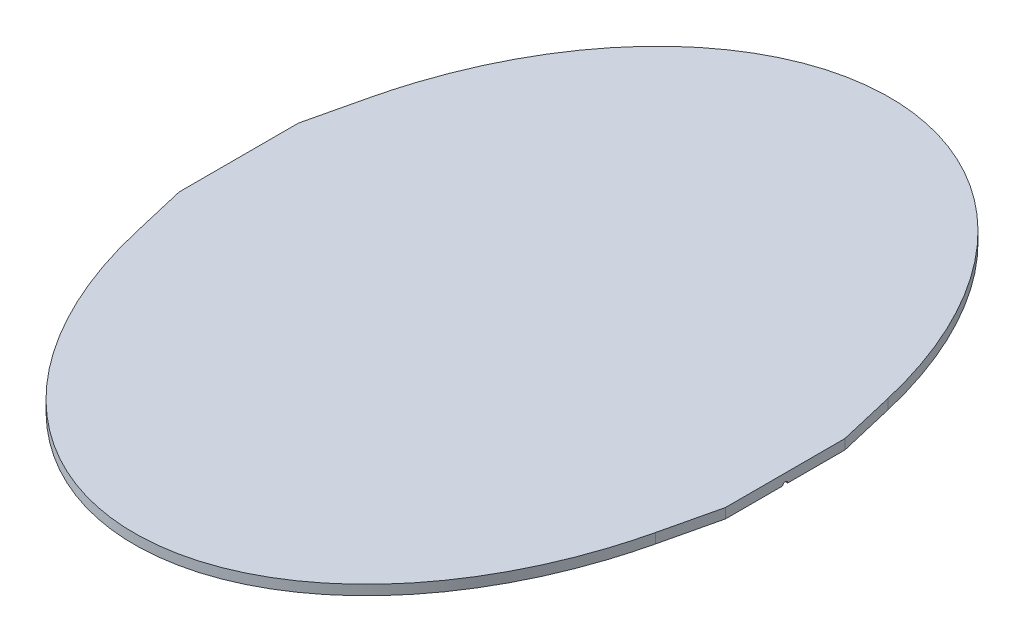
from build123d import *

# Parameters (mm, degrees)
SKETCH1_RX          = 380
SKETCH1_RY          = 275
BOSS_EXTRUDE1_DEPTH = 10
BOSS_EXTRUDE2_DEPTH = 10
CUT_EXTRUDE1_DEPTH  = 10
CUT_EXTRUDE2_DEPTH  = 10


with BuildPart() as part:
    # Sketch1 → Boss-Extrude1 (new body)
    with BuildSketch(Plane(origin=(0, 0, 0), x_dir=(1, 0, 0), z_dir=(0, 1, 0))):
        with Locations(Location((0, 0), (0, 0, 90))):
            Ellipse(SKETCH1_RX, SKETCH1_RY)
    extrude(amount=BOSS_EXTRUDE1_DEPTH)

    # Sketch2 → Boss-Extrude2 (add)
    with BuildSketch(Plane(origin=(0, 10, 0), x_dir=(-1, 0, 0), z_dir=(0, 1, 0))):
        Polygon((-261.621621622, -117.081081081), (-275, -60), (-275, 0), (-275, 60), (-261.621621622, 117.081081081), align=None)
        Polygon((261.621621622, 117.081081081), (261.621621622, -117.081081081), (275, -60), (275, 0), (275, 60), align=None)
    extrude(amount=-BOSS_EXTRUDE2_DEPTH)

    # Sketch3 → Cut-Extrude1 (cut)
    with BuildSketch(Plane(origin=(275, 0, 0), x_dir=(0, 0, -1), z_dir=(1, 0, 0))):
        with BuildLine():
            Line((-2.5, 0), (2.5, 0))
            ThreePointArc((2.5, 0), (0, 2.5), (-2.5, 0))
        make_face()
    extrude(amount=-CUT_EXTRUDE1_DEPTH, mode=Mode.SUBTRACT)

    # Sketch4 → Cut-Extrude2 (cut)
    with BuildSketch(Plane.ZY.offset(275)):
        with BuildLine():
            Line((-2.5, 0), (2.5, 0))
            ThreePointArc((2.5, 0), (0, 2.5), (-2.5, 0))
        make_face()
    extrude(amount=-CUT_EXTRUDE2_DEPTH, mode=Mode.SUBTRACT)


solid = part.part
